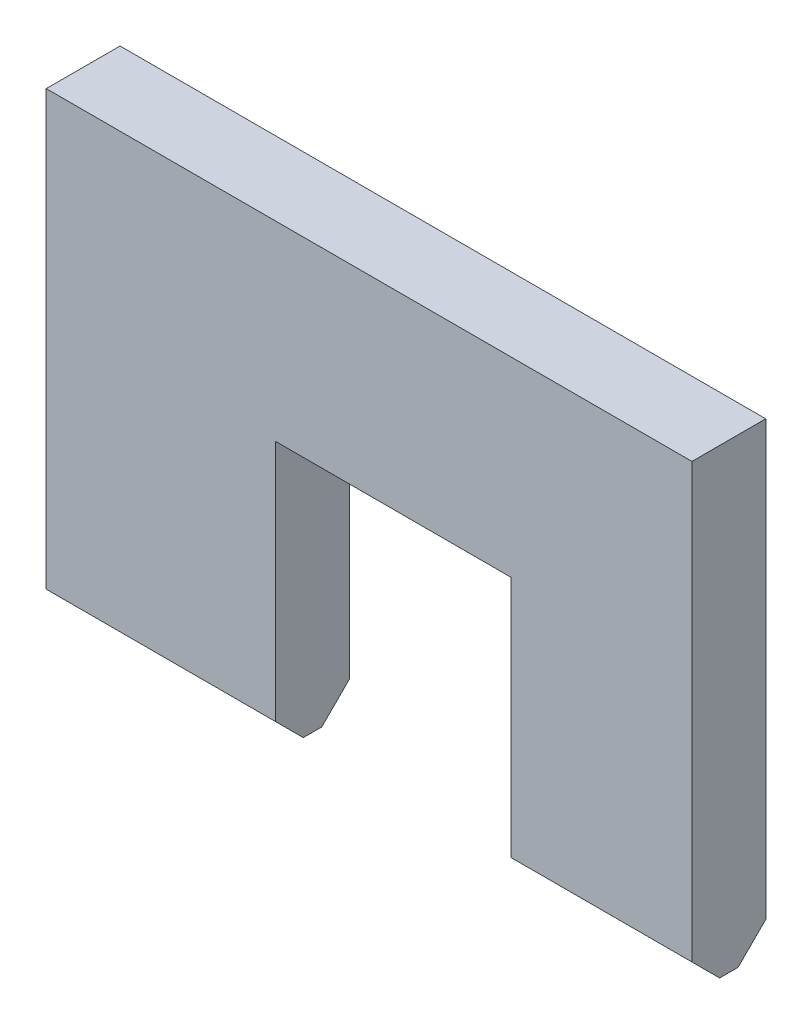
from build123d import *

# Parameters (mm, degrees)
SKETCH_1_W          = 35
SKETCH_1_H          = 4
EXTRUDE_1_DEPTH     = 25
CHAMFER_1_SIZE      = 1.5
SKETCH_2_W          = 12.744138526
SKETCH_2_H          = 17.309109507
CUT_EXTRUDE_1_DEPTH = 10


with BuildPart() as part:
    # 草图1 → 凸台-拉伸1 (new body)
    with BuildSketch(Plane(origin=(0, 0, 0), x_dir=(1, 0, 0), z_dir=(0, 1, 0))):
        Rectangle(SKETCH_1_W, SKETCH_1_H)
    extrude(amount=EXTRUDE_1_DEPTH)

    # 倒角1
    chamfer_1_edges = [part.edges().sort_by_distance(p)[0] for p in [
        (0, 0, 2),
        (0, 0, -2),
    ]]
    chamfer(chamfer_1_edges, length=CHAMFER_1_SIZE)

    # 草图2 → 切除-拉伸1 (cut)
    with BuildSketch(Plane(origin=(0, 0, -2), x_dir=(-1, 0, 0), z_dir=(0, 0, -1))):
        with Locations((-1.305884938, 6.001185717)):
            Rectangle(SKETCH_2_W, SKETCH_2_H)
    extrude(amount=-CUT_EXTRUDE_1_DEPTH, mode=Mode.SUBTRACT)


solid = part.part
